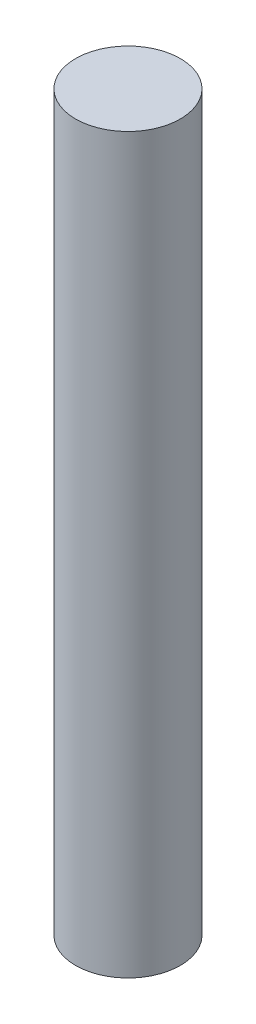
from build123d import *

# Parameters (mm, degrees)
ESQUISSE1_R      = 1
EXTRUSION1_DEPTH = 14


with BuildPart() as part:
    # Esquisse1 → Extrusion1 (new body)
    with BuildSketch(Plane(origin=(0, 0, 0), x_dir=(1, 0, 0), z_dir=(0, 1, 0))):
        Circle(ESQUISSE1_R)
    extrude(amount=EXTRUSION1_DEPTH)


solid = part.part
